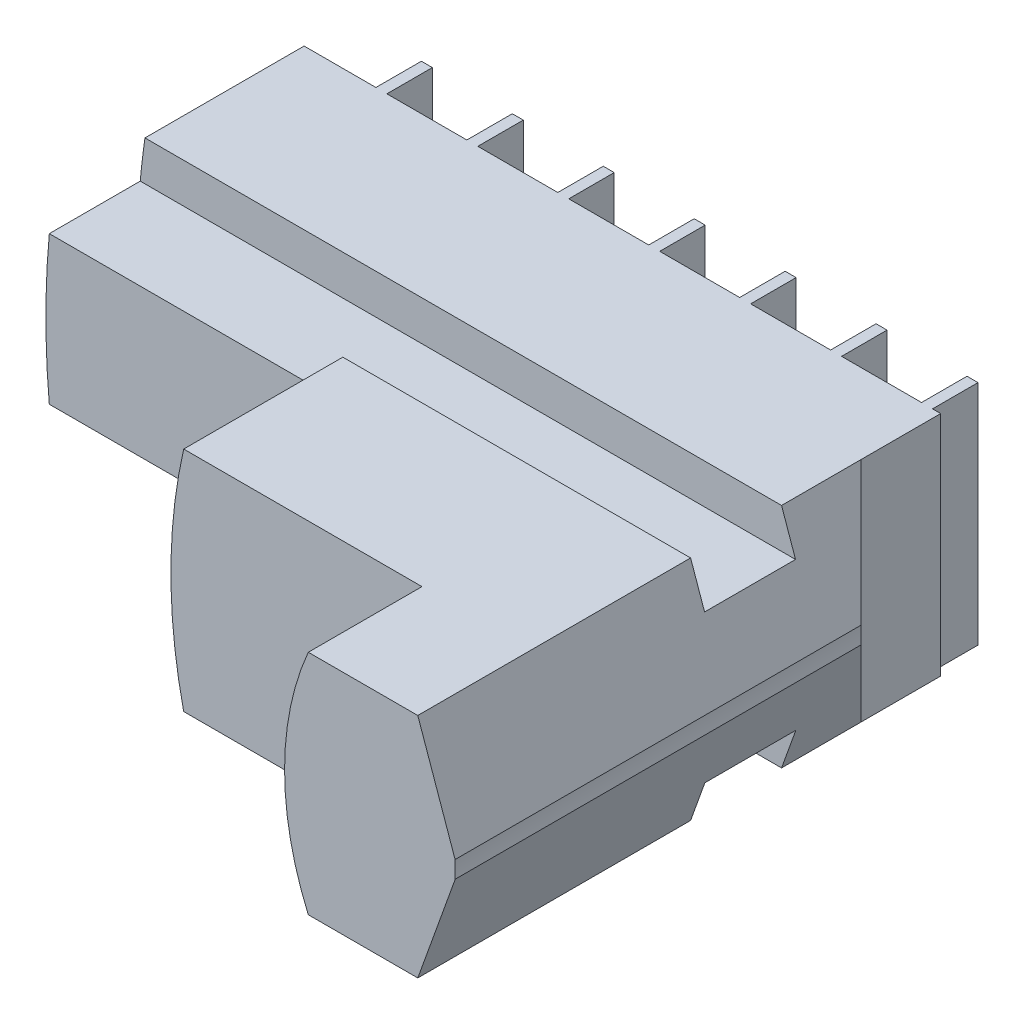
from build123d import *

# Parameters (mm, degrees)
BOSS_EXTRUDE1_DEPTH     = 22
BOSS_EXTRUDE2_DEPTH     = 36
BOSS_EXTRUDE3_DEPTH     = 46
SKETCH4_W               = 8
SKETCH4_H               = 3.5
CUT_EXTRUDE1_DEPTH      = 77.27226798
CUT_EXTRUDE3_DEPTH      = 85.356386836
CUT_EXTRUDE3_DEPTH_BACK = 85.356386836
BOSS_EXTRUDE4_DEPTH     = 4
LPATTERN1_COUNT         = 7
LPATTERN1_PITCH         = 8


with BuildPart() as part:
    # Sketch1 → Boss-Extrude1 (new body)
    with BuildSketch(Plane.XY):
        with BuildLine():
            Line((-69.282032303, -10), (-43.874821937, -10))
            ThreePointArc((-43.874821937, -10), (-45, 0), (-43.874821937, 10))
            Line((-43.874821937, 10), (-69.282032303, 10))
            ThreePointArc((-69.282032303, 10), (-70, 0), (-69.282032303, -10))
        make_face()
    extrude(amount=BOSS_EXTRUDE1_DEPTH)

    # Sketch1_3 → Boss-Extrude2 (add)
    with BuildSketch(Plane.XY):
        with BuildLine():
            Line((-43.874821937, -10), (-22.912878475, -10))
            ThreePointArc((-22.912878475, -10), (-25, 0), (-22.912878475, 10))
            Line((-22.912878475, 10), (-43.874821937, 10))
            ThreePointArc((-43.874821937, 10), (-45, 0), (-43.874821937, -10))
        make_face()
    extrude(amount=BOSS_EXTRUDE2_DEPTH)

    # Sketch1_4 → Boss-Extrude3 (add)
    with BuildSketch(Plane.XY):
        with BuildLine():
            Line((-22.912878475, -10), (-13.282032303, -10))
            Line((-13.282032303, -10), (-9.987844042, -0.827246844))
            ThreePointArc((-9.987844042, -0.827246844), (-10.021711204, -0.081673003), (-10, 0.664353779))
            Line((-10, 0.664353779), (-13.282032303, 10))
            Line((-13.282032303, 10), (-22.912878475, 10))
            ThreePointArc((-22.912878475, 10), (-25, 0), (-22.912878475, -10))
        make_face()
    extrude(amount=BOSS_EXTRUDE3_DEPTH)

    # Sketch4 → Cut-Extrude1 (cut, through all)
    with BuildSketch(Plane.ZY.offset(70)):
        with Locations((18, 8.25)):
            Rectangle(SKETCH4_W, SKETCH4_H)
        with Locations((18, -8.25)):
            Rectangle(SKETCH4_W, SKETCH4_H)
    extrude(amount=-CUT_EXTRUDE1_DEPTH, mode=Mode.SUBTRACT)

    # Sketch8 → Cut-Extrude3 (cut, two sides: drawn at the far end of the back side and taken through both)
    with BuildSketch(Plane(origin=(0, 0, 0), x_dir=(1, 0, 0), z_dir=(0, 1, 0)).offset(-CUT_EXTRUDE3_DEPTH_BACK)):
        Polygon((-13.282032303, -7), (-9.987844042, -10.294188261), (-9.987844042, 0), (-13.282032303, 0), align=None)
    extrude(amount=CUT_EXTRUDE3_DEPTH + CUT_EXTRUDE3_DEPTH_BACK, mode=Mode.SUBTRACT)

    # Sketch7 → Boss-Extrude4 (add)
    with BuildSketch(Plane(origin=(0, 0, 0), x_dir=(-1, 0, 0), z_dir=(0, 0, -1))):
        with BuildLine():
            Line((14, 10), (14, -10))
            Line((14, -10), (14.966629547, -10))
            ThreePointArc((14.966629547, -10), (18, 0), (14.966629547, 10))
            Line((14.966629547, 10), (14, 10))
        make_face()
    boss_extrude4 = extrude(amount=BOSS_EXTRUDE4_DEPTH)

    # LPattern1: Boss-Extrude4 ×7
    with Locations(*[(-i * LPATTERN1_PITCH, 0, 0) for i in range(1, LPATTERN1_COUNT)]):
        add(boss_extrude4)


solid = part.part
